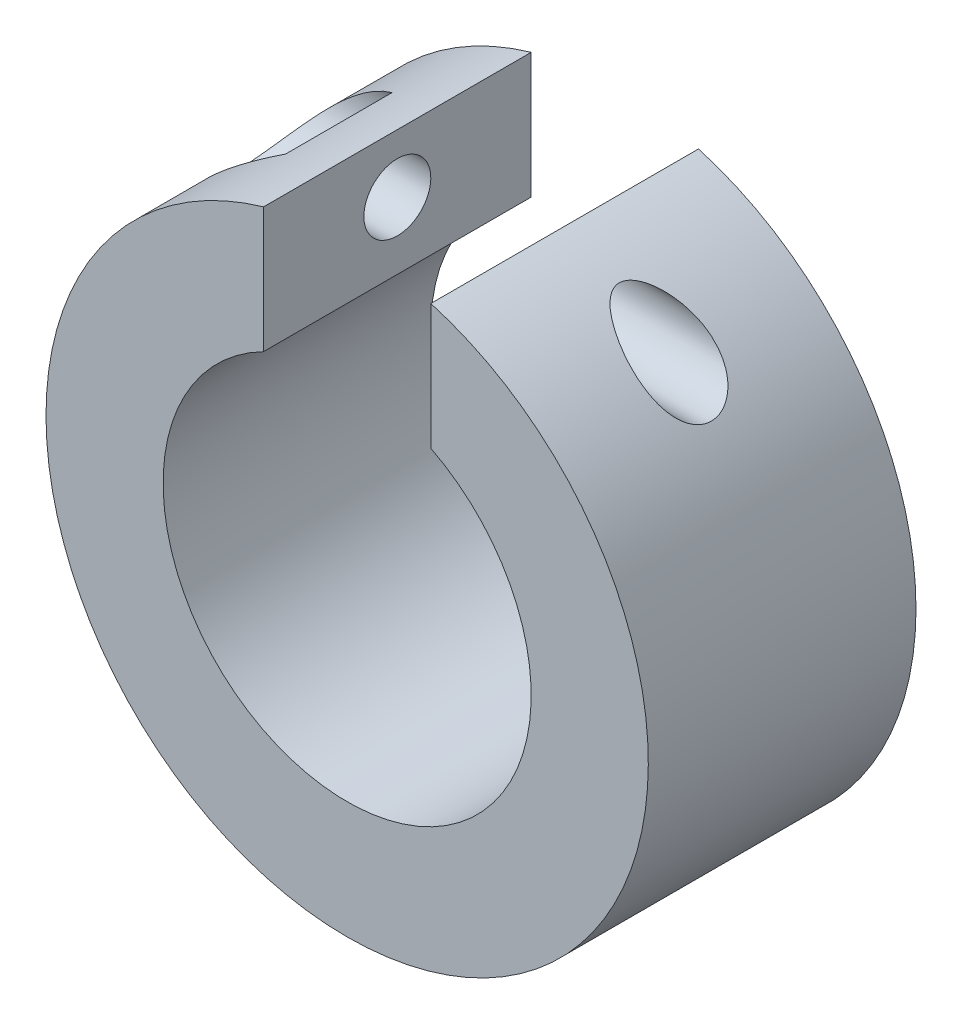
from build123d import *

# Parameters (mm, degrees)
ESQUISSE1_R                  = 9
ESQUISSE1_R_2                = 5.5
BOSS_EXTRU_1_DEPTH           = 8
ENL_V_MAT_EXTRU_1_REACH      = 10
ESQUISSE2_W                  = 5
ESQUISSE2_H                  = 8
ENL_V_MAT_EXTRU_2_REACH      = 8.5
ESQUISSE8_R                  = 1
D_GAGEMENT_M21_D             = 2.2
D_GAGEMENT_M21_DEPTH         = 4.5
ESQUISSE21_R                 = 1.9
ENL_V_MAT_EXTRU_4_DEPTH      = 2.75
ENL_V_MAT_EXTRU_4_DEPTH_BACK = 2.75


with BuildPart() as part:
    # Esquisse1 → Boss.-Extru.1 (new body)
    with BuildSketch(Plane.XY):
        Circle(ESQUISSE1_R)
        Circle(ESQUISSE1_R_2, mode=Mode.SUBTRACT)
    extrude(amount=BOSS_EXTRU_1_DEPTH)

    # Esquisse2 → Enl_v. mat.-Extru.1 (cut, up to next)
    with BuildSketch(Plane.XY.offset(8), mode=Mode.PRIVATE) as enl_v_mat_extru_1_sk1:
        with Locations((0, 7)):
            Rectangle(ESQUISSE2_W, ESQUISSE2_H)
    enl_v_mat_extru_1_tool1 = extrude(enl_v_mat_extru_1_sk1.sketch, amount=-ENL_V_MAT_EXTRU_1_REACH, mode=Mode.PRIVATE) & part.part
    add(enl_v_mat_extru_1_tool1.solids().sort_by_distance((0, 7, 8))[0], mode=Mode.SUBTRACT)

    # Esquisse8 → Enl_v. mat.-Extru.2 (cut, up to next)
    with BuildSketch(Plane(origin=(-2.5, 0, 0), x_dir=(0, 0, -1), z_dir=(1, 0, 0)), mode=Mode.PRIVATE) as enl_v_mat_extru_2_sk1:
        with Locations((-4, 6.895808233)):
            Circle(ESQUISSE8_R)
    enl_v_mat_extru_2_tool1 = extrude(enl_v_mat_extru_2_sk1.sketch, amount=-ENL_V_MAT_EXTRU_2_REACH, mode=Mode.PRIVATE) & part.part
    add(enl_v_mat_extru_2_tool1.solids().sort_by_distance((-2.5, 6.895808, 4))[0], mode=Mode.SUBTRACT)

    # D_gagement M21
    with Locations(Plane(origin=(7, 0, 0), x_dir=(0, 0, 1), z_dir=(1, 0, 0))):
        with Locations((4, -6.895808233)):
            Hole(D_GAGEMENT_M21_D / 2, depth=D_GAGEMENT_M21_DEPTH)

    # Esquisse21 → Enl_v. mat.-Extru.4 (cut, two sides)
    with BuildSketch(Plane(origin=(-7, 0, 0), x_dir=(0, 0, -1), z_dir=(1, 0, 0))) as enl_v_mat_extru_4_sk:
        with Locations((-4, 6.895808233)):
            Circle(ESQUISSE21_R)
    extrude(amount=ENL_V_MAT_EXTRU_4_DEPTH, mode=Mode.SUBTRACT)
    extrude(enl_v_mat_extru_4_sk.sketch, amount=-ENL_V_MAT_EXTRU_4_DEPTH_BACK, mode=Mode.SUBTRACT)


solid = part.part
